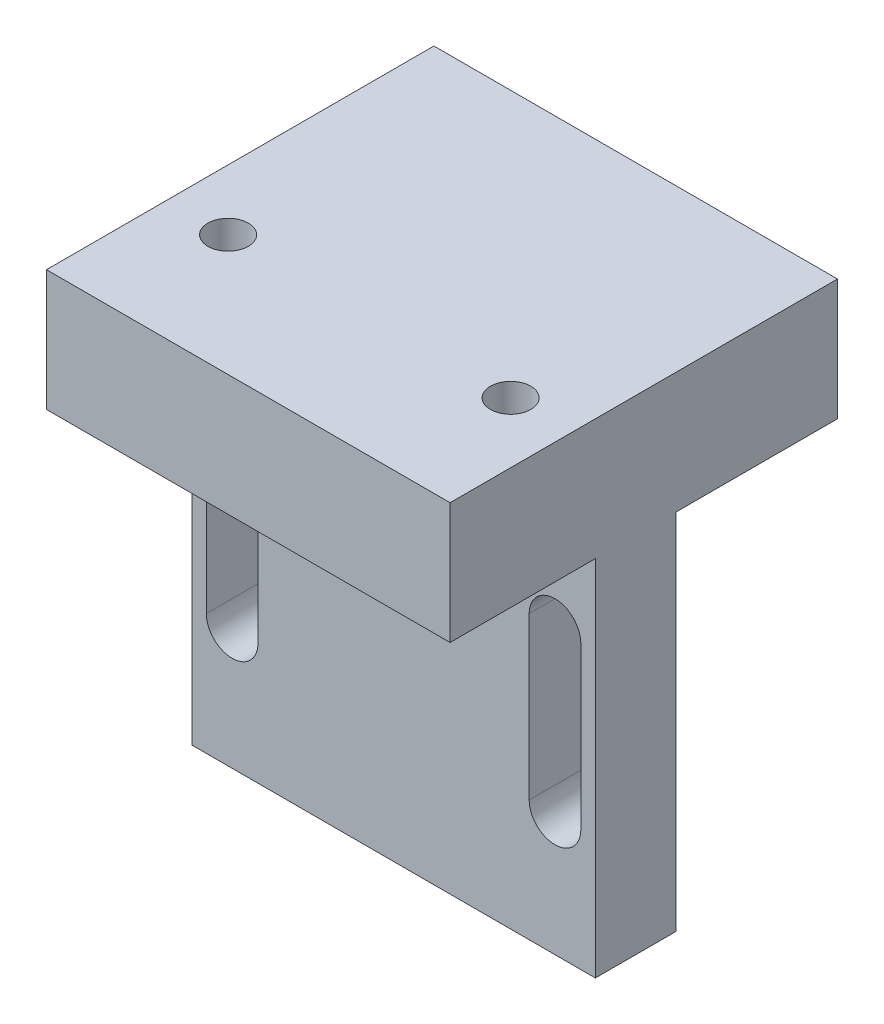
from build123d import *

# Parameters (mm, degrees)
SKETCH_1_W             = 50
SKETCH_1_H             = 60
EXTRUDE_1_DEPTH        = 30
SKETCH_2_W             = 50
SKETCH_2_H             = 45
CUT_EXTRUDE_1_DEPTH    = 20
CUT_EXTRUDE_2_DEPTH    = 11
SKETCH_6_W             = 50
SKETCH_6_H             = 15
EXTRUDE_2_DEPTH        = 18
HOLE_WIZARD_M6_1_D     = 5
HOLE_WIZARD_M6_1_DEPTH = 15
HOLE_WIZARD_M6_1_TIP   = 1.502151548


with BuildPart() as part:
    # 草图1 → 凸台-拉伸1 (new body)
    with BuildSketch(Plane.XY):
        Rectangle(SKETCH_1_W, SKETCH_1_H)
    extrude(amount=EXTRUDE_1_DEPTH)

    # 草图2 → 切除-拉伸1 (cut)
    with BuildSketch(Plane(origin=(0, 0, 0), x_dir=(-1, 0, 0), z_dir=(0, 0, -1))):
        with Locations((0, -7.5)):
            Rectangle(SKETCH_2_W, SKETCH_2_H)
    extrude(amount=-CUT_EXTRUDE_1_DEPTH, mode=Mode.SUBTRACT)

    # 草图3 → 切除-拉伸2 (cut, through all)
    with BuildSketch(Plane(origin=(0, 0, 20), x_dir=(-1, 0, 0), z_dir=(0, 0, -1))):
        with BuildLine():
            Line((-23.2, -15), (-23.2, 5))
            ThreePointArc((-23.2, 5), (-20, 8.2), (-16.8, 5))
            Line((-16.8, 5), (-16.8, -15))
            ThreePointArc((-16.8, -15), (-20, -18.2), (-23.2, -15))
        make_face()
        with BuildLine():
            Line((23.2, -15), (23.2, 5))
            ThreePointArc((23.2, 5), (20, 8.2), (16.8, 5))
            Line((16.8, 5), (16.8, -15))
            ThreePointArc((16.8, -15), (20, -18.2), (23.2, -15))
        make_face()
    extrude(amount=-CUT_EXTRUDE_2_DEPTH, mode=Mode.SUBTRACT)

    # 草图6 → 凸台-拉伸2 (add)
    with BuildSketch(Plane.XY.offset(30)):
        with Locations((0, 22.5)):
            Rectangle(SKETCH_6_W, SKETCH_6_H)
    extrude(amount=EXTRUDE_2_DEPTH)

    # M6 螺纹孔1
    with Locations(Plane(origin=(17.5, 30, 33), x_dir=(1, 0, 0), z_dir=(0, 1, 0))):
        with Locations((0, 0), (-35, 0)):
            Hole(HOLE_WIZARD_M6_1_D / 2, depth=HOLE_WIZARD_M6_1_DEPTH)
            with Locations((0, 0, -(HOLE_WIZARD_M6_1_DEPTH + HOLE_WIZARD_M6_1_TIP / 2))):  # 118° drill point
                Cone(0, HOLE_WIZARD_M6_1_D / 2, HOLE_WIZARD_M6_1_TIP, mode=Mode.SUBTRACT)


solid = part.part
